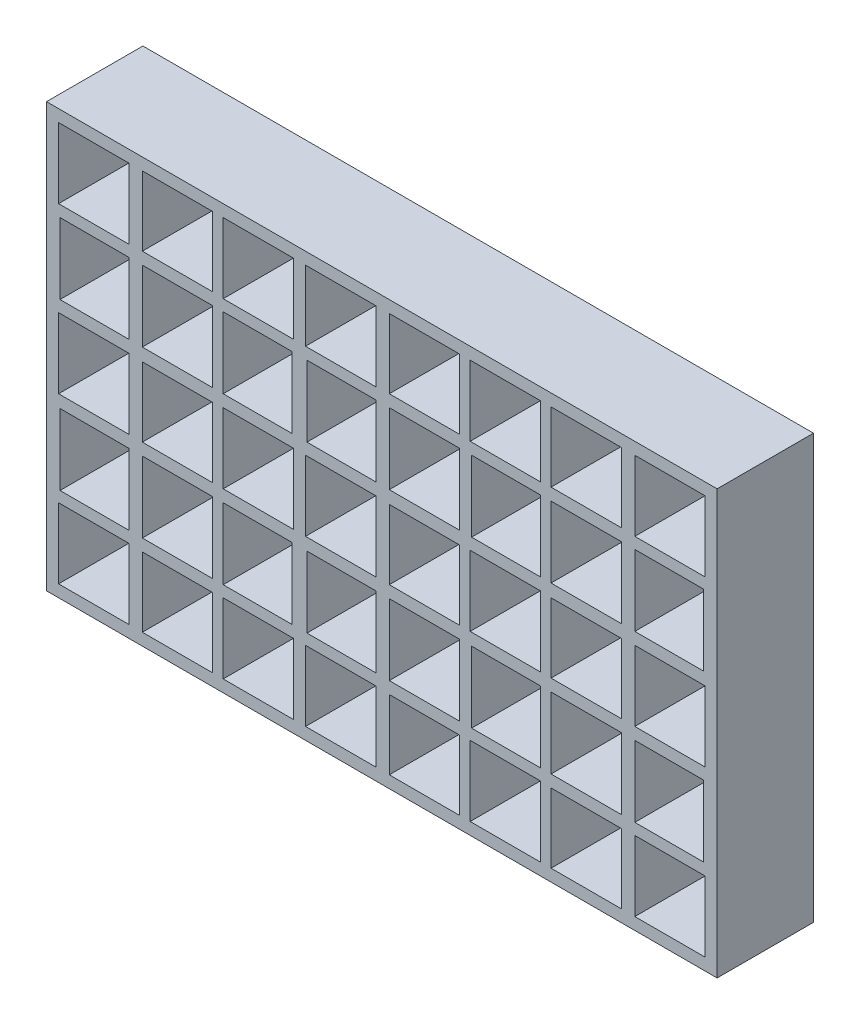
from build123d import *

# Parameters (mm, degrees)
SKETCH1_W           = 334
SKETCH1_H           = 211
SKETCH1_W_2         = 34.277630703
SKETCH1_H_2         = 35.361184648
SKETCH1_W_3         = 35
SKETCH1_H_3         = 35
SKETCH1_H_4         = 34.638815352
BOSS_EXTRUDE1_DEPTH = 45
SKETCH2_W           = 334
SKETCH2_H           = 211
BOSS_EXTRUDE2_DEPTH = 3


with BuildPart() as part:
    # Sketch1 → Boss-Extrude1 (new body)
    with BuildSketch(Plane.XY):
        Rectangle(SKETCH1_W, SKETCH1_H)
        with Locations((143.138815351, 41.180592324)):
            Rectangle(SKETCH1_W_2, SKETCH1_H_2, mode=Mode.SUBTRACT)
        with Locations((143.5, 82)):
            Rectangle(SKETCH1_W_3, SKETCH1_H_3, mode=Mode.SUBTRACT)
        with Locations((61.5, 82)):
            Rectangle(SKETCH1_W_3, SKETCH1_H_3, mode=Mode.SUBTRACT)
        with Locations((61.861184649, 41.180592324)):
            Rectangle(SKETCH1_W_2, SKETCH1_H_2, mode=Mode.SUBTRACT)
        with Locations((101.777630703, 82.180592324)):
            Rectangle(SKETCH1_W_3, SKETCH1_H_4, mode=Mode.SUBTRACT)
        with Locations((101.777630703, 41.180592324)):
            Rectangle(SKETCH1_W_3, SKETCH1_H_2, mode=Mode.SUBTRACT)
        with Locations((143.138815351, -41.180592324)):
            Rectangle(SKETCH1_W_2, SKETCH1_H_2, mode=Mode.SUBTRACT)
        with Locations((101.777630703, -41.180592324)):
            Rectangle(SKETCH1_W_3, SKETCH1_H_2, mode=Mode.SUBTRACT)
        with Locations((61.861184649, -41.180592324)):
            Rectangle(SKETCH1_W_2, SKETCH1_H_2, mode=Mode.SUBTRACT)
        with Locations((61.5, -82)):
            Rectangle(SKETCH1_W_3, SKETCH1_H_3, mode=Mode.SUBTRACT)
        with Locations((101.777630703, -82.180592324)):
            Rectangle(SKETCH1_W_3, SKETCH1_H_4, mode=Mode.SUBTRACT)
        with Locations((143.5, -82)):
            Rectangle(SKETCH1_W_3, SKETCH1_H_3, mode=Mode.SUBTRACT)
        with Locations((-143.5, -82)):
            Rectangle(SKETCH1_W_3, SKETCH1_H_3, mode=Mode.SUBTRACT)
        with Locations((-101.777630703, -82.180592324)):
            Rectangle(SKETCH1_W_3, SKETCH1_H_4, mode=Mode.SUBTRACT)
        with Locations((-61.5, -82)):
            Rectangle(SKETCH1_W_3, SKETCH1_H_3, mode=Mode.SUBTRACT)
        with Locations((-61.861184649, -41.180592324)):
            Rectangle(SKETCH1_W_2, SKETCH1_H_2, mode=Mode.SUBTRACT)
        with Locations((-101.777630703, -41.180592324)):
            Rectangle(SKETCH1_W_3, SKETCH1_H_2, mode=Mode.SUBTRACT)
        with Locations((-143.138815351, -41.180592324)):
            Rectangle(SKETCH1_W_2, SKETCH1_H_2, mode=Mode.SUBTRACT)
        with Locations((-143.138815351, 41.180592324)):
            Rectangle(SKETCH1_W_2, SKETCH1_H_2, mode=Mode.SUBTRACT)
        with Locations((-101.777630703, 41.180592324)):
            Rectangle(SKETCH1_W_3, SKETCH1_H_2, mode=Mode.SUBTRACT)
        with Locations((-61.861184649, 41.180592324)):
            Rectangle(SKETCH1_W_2, SKETCH1_H_2, mode=Mode.SUBTRACT)
        with Locations((-61.5, 82)):
            Rectangle(SKETCH1_W_3, SKETCH1_H_3, mode=Mode.SUBTRACT)
        with Locations((-101.777630703, 82.180592324)):
            Rectangle(SKETCH1_W_3, SKETCH1_H_4, mode=Mode.SUBTRACT)
        with Locations((-143.5, 82)):
            Rectangle(SKETCH1_W_3, SKETCH1_H_3, mode=Mode.SUBTRACT)
        with Locations((61.5, 0)):
            Rectangle(SKETCH1_W_3, SKETCH1_H_3, mode=Mode.SUBTRACT)
        with Locations((101.777630703, -0.180592324)):
            Rectangle(SKETCH1_W_3, SKETCH1_H_4, mode=Mode.SUBTRACT)
        with Locations((143.5, 0)):
            Rectangle(SKETCH1_W_3, SKETCH1_H_3, mode=Mode.SUBTRACT)
        with Locations((-143.5, 0)):
            Rectangle(SKETCH1_W_3, SKETCH1_H_3, mode=Mode.SUBTRACT)
        with Locations((-101.777630703, -0.180592324)):
            Rectangle(SKETCH1_W_3, SKETCH1_H_4, mode=Mode.SUBTRACT)
        with Locations((-61.5, 0)):
            Rectangle(SKETCH1_W_3, SKETCH1_H_3, mode=Mode.SUBTRACT)
        with Locations((-20.5, 82)):
            Rectangle(SKETCH1_W_3, SKETCH1_H_3, mode=Mode.SUBTRACT)
        with Locations((-20.138815351, 41.180592324)):
            Rectangle(SKETCH1_W_2, SKETCH1_H_2, mode=Mode.SUBTRACT)
        with Locations((-20.5, 0)):
            Rectangle(SKETCH1_W_3, SKETCH1_H_3, mode=Mode.SUBTRACT)
        with Locations((-20.138815351, -41.180592324)):
            Rectangle(SKETCH1_W_2, SKETCH1_H_2, mode=Mode.SUBTRACT)
        with Locations((-20.5, -82)):
            Rectangle(SKETCH1_W_3, SKETCH1_H_3, mode=Mode.SUBTRACT)
        with Locations((21.222369297, -82.180592324)):
            Rectangle(SKETCH1_W_3, SKETCH1_H_4, mode=Mode.SUBTRACT)
        with Locations((21.222369297, -41.180592324)):
            Rectangle(SKETCH1_W_3, SKETCH1_H_2, mode=Mode.SUBTRACT)
        with Locations((21.222369297, -0.180592324)):
            Rectangle(SKETCH1_W_3, SKETCH1_H_4, mode=Mode.SUBTRACT)
        with Locations((21.222369297, 41.180592324)):
            Rectangle(SKETCH1_W_3, SKETCH1_H_2, mode=Mode.SUBTRACT)
        with Locations((21.222369297, 82.180592324)):
            Rectangle(SKETCH1_W_3, SKETCH1_H_4, mode=Mode.SUBTRACT)
    extrude(amount=BOSS_EXTRUDE1_DEPTH)

    # Sketch2 → Boss-Extrude2 (add)
    with BuildSketch(Plane(origin=(0, 0, 0), x_dir=(-1, 0, 0), z_dir=(0, 0, -1))):
        Rectangle(SKETCH2_W, SKETCH2_H)
    extrude(amount=BOSS_EXTRUDE2_DEPTH)


solid = part.part
